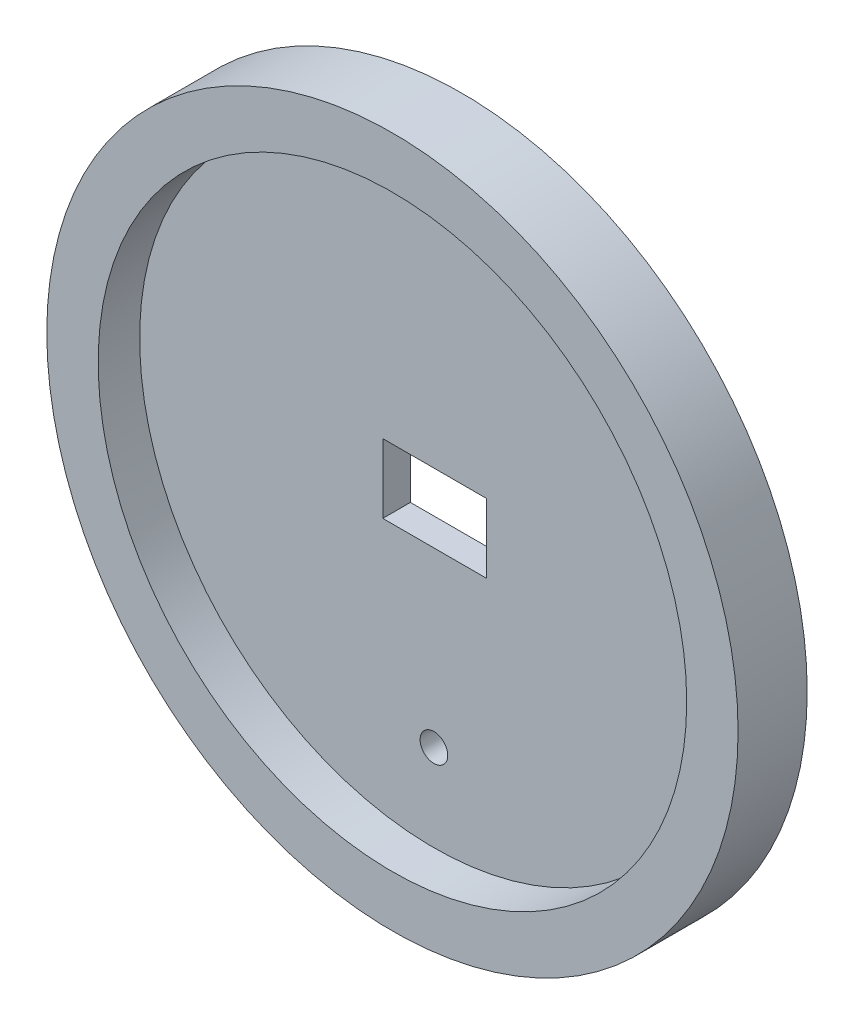
from build123d import *

# Parameters (mm, degrees)
ESQUISSE1_R             = 25
ESQUISSE1_R_2           = 1
ESQUISSE1_W             = 7.5
ESQUISSE1_H             = 5
BOSS_EXTRU_1_DEPTH      = 5
ESQUISSE2_R             = 21.284112143
ENL_V_MAT_EXTRU_1_DEPTH = 3


with BuildPart() as part:
    # Esquisse1 → Boss.-Extru.1 (new body)
    with BuildSketch(Plane.XY):
        Circle(ESQUISSE1_R)
        with Locations((0, -15)):
            Circle(ESQUISSE1_R_2, mode=Mode.SUBTRACT)
        with Locations((0.05, 0)):
            Rectangle(ESQUISSE1_W, ESQUISSE1_H, mode=Mode.SUBTRACT)
    extrude(amount=BOSS_EXTRU_1_DEPTH)

    # Esquisse2 → Enlèv. mat.-Extru.1 (cut)
    with BuildSketch(Plane.XY.offset(5)):
        Circle(ESQUISSE2_R)
    extrude(amount=-ENL_V_MAT_EXTRU_1_DEPTH, mode=Mode.SUBTRACT)


solid = part.part
